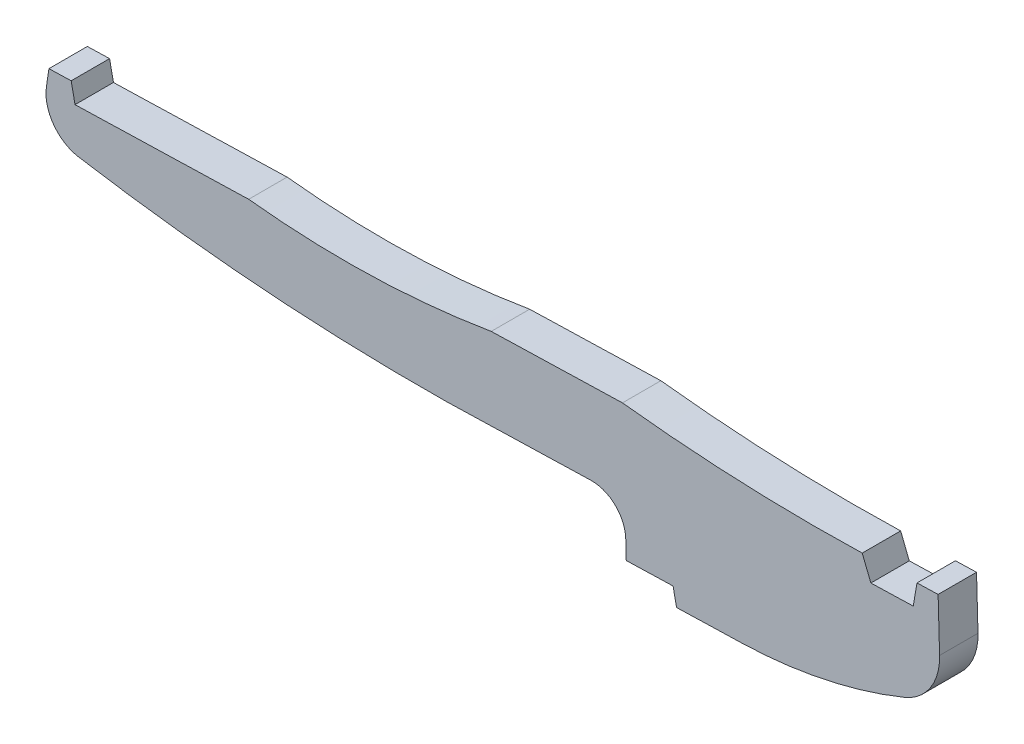
from build123d import *

# Parameters (mm, degrees)
BOSS_EXTRUDE1_DEPTH = 6.8


with BuildPart() as part:
    # Sketch1 → Boss-Extrude1 (new body)
    with BuildSketch(Plane.XY):
        with BuildLine():
            Line((-3.736553352, -0.105475371), (0, 0))
            Line((0, 0), (0.260408581, -9.22519204))
            ThreePointArc((0.260408581, -9.22519204), (-1.360098109, -14.970948565), (-5.965617029, -18.769495059))
            ThreePointArc((-5.965617029, -18.769495059), (-20.103980037, -23.096122462), (-34.787070991, -24.833894972))
            Line((-34.787070991, -24.833894972), (-46.296555972, -25.15878454))
            Line((-46.296555972, -25.15878454), (-46.909976525, -22.174905175))
            Line((-46.909976525, -22.174905175), (-55.197899778, -22.408856547))
            Line((-55.197899778, -22.408856547), (-55.292212243, -19.06775851))
            ThreePointArc((-55.292212243, -19.06775851), (-57.168585337, -14.876394082), (-61.459123685, -13.239448011))
            Line((-61.459123685, -13.239448011), (-86.952751483, -13.959081751))
            ThreePointArc((-86.952751483, -13.959081751), (-119.784800915, -12.909412184), (-152.397282866, -8.976055209))
            ThreePointArc((-152.397282866, -8.976055209), (-156.666477303, -6.118238551), (-157.834820075, -1.115428104))
            Line((-157.834820075, -1.115428104), (-157.390699994, 1.898303501))
            Line((-157.390699994, 1.898303501), (-153.450231486, 2.009534988))
            Line((-153.450231486, 2.009534988), (-152.767576007, -1.311125833))
            Line((-152.767576007, -1.311125833), (-122.028102345, -0.443412436))
            ThreePointArc((-122.028102345, -0.443412436), (-100.521194384, -1.324753836), (-79.098250735, 0.768410766))
            Line((-79.098250735, 0.768410766), (-55.870655521, 1.424078972))
            ThreePointArc((-55.870655521, 1.424078972), (-34.68336237, -0.227804683), (-13.432310629, -0.379167061))
            Line((-13.432310629, -0.379167061), (-11.903069428, -4.205729222))
            Line((-11.903069428, -4.205729222), (-4.406055716, -3.994103632))
            Line((-4.406055716, -3.994103632), (-3.736553352, -0.105475371))
        make_face()
    extrude(amount=BOSS_EXTRUDE1_DEPTH)


solid = part.part
